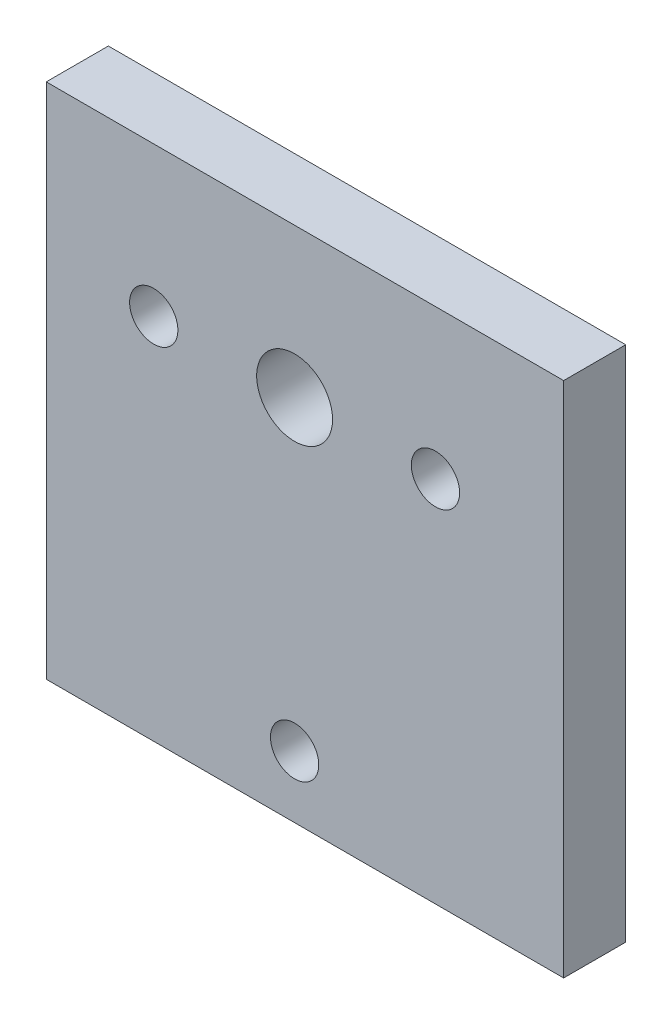
from build123d import *

# Parameters (mm, degrees)
SKETCH1_W           = 37.5
SKETCH1_H           = 37.5
SKETCH1_R           = 2.75
SKETCH1_R_2         = 1.75
BOSS_EXTRUDE1_DEPTH = 4.5


with BuildPart() as part:
    # Sketch1 → Boss-Extrude1 (new body)
    with BuildSketch(Plane.XY):
        Rectangle(SKETCH1_W, SKETCH1_H)
        with Locations((-0.75, 7.92918)):
            Circle(SKETCH1_R, mode=Mode.SUBTRACT)
        with Locations((9.46, 7.92918)):
            Circle(SKETCH1_R_2, mode=Mode.SUBTRACT)
        with Locations((-10.96, 7.92918)):
            Circle(SKETCH1_R_2, mode=Mode.SUBTRACT)
        with Locations((-0.75, -14.25)):
            Circle(SKETCH1_R_2, mode=Mode.SUBTRACT)
    extrude(amount=BOSS_EXTRUDE1_DEPTH)


solid = part.part
